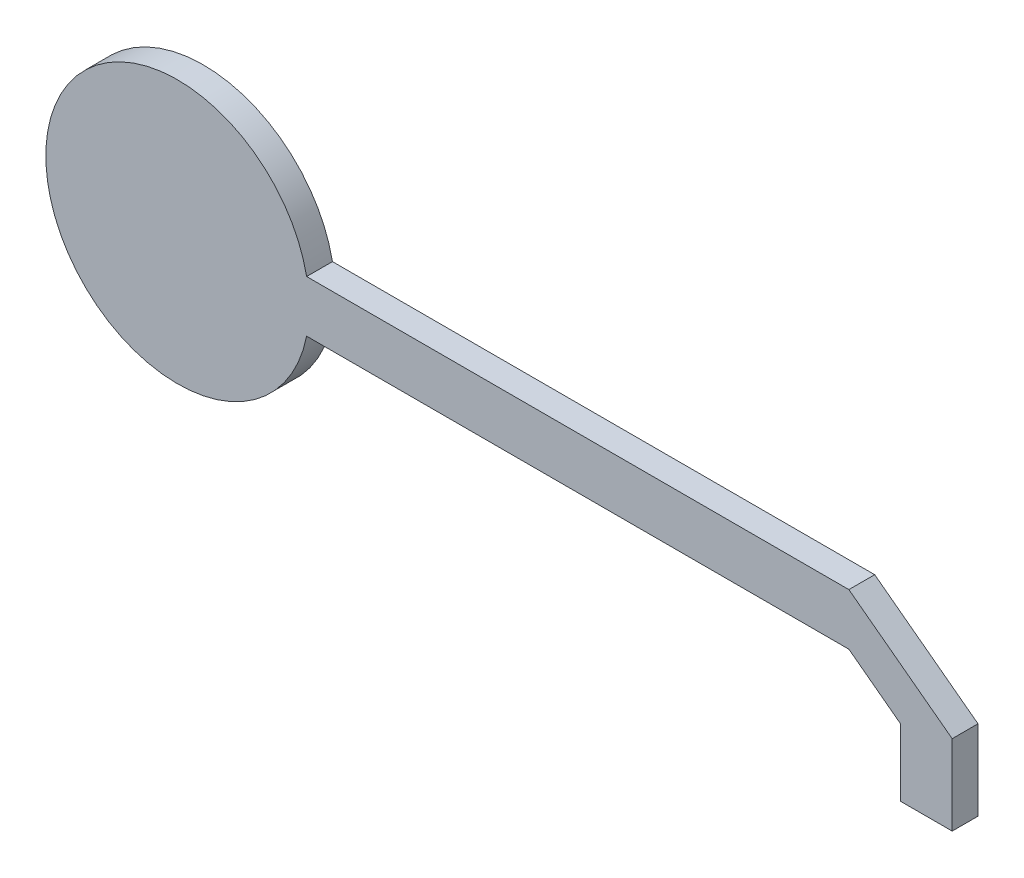
from build123d import *

# Parameters (mm, degrees)
SALIENTE_EXTRUIR1_DEPTH = 5
CROQUIS3_R              = 2.5
SALIENTE_EXTRUIR3_DEPTH = 5
CROQUIS4_R              = 5
SALIENTE_EXTRUIR4_DEPTH = 10


with BuildPart() as part:
    # Croquis1 → Saliente-Extruir1 (new body)
    with BuildSketch(Plane.XY):
        with BuildLine():
            Line((-52.49750025, 5), (52.49750025, 5))
            Line((52.49750025, 5), (72.49750025, -10))
            Line((72.49750025, -10), (72.49750025, -25.5))
            Line((72.49750025, -25.5), (62.49750025, -25.5))
            Line((62.49750025, -25.5), (62.49750025, -12.5))
            Line((62.49750025, -12.5), (52.49750025, -5))
            Line((52.49750025, -5), (-52.49750025, -5))
            ThreePointArc((-52.49750025, -5), (-103.00249975, 0), (-52.49750025, 5))
        make_face()
    extrude(amount=SALIENTE_EXTRUIR1_DEPTH)

    # Croquis3 → Saliente-Extruir3 (add)
    with BuildSketch(Plane(origin=(0, 0, 0), x_dir=(-1, 0, 0), z_dir=(0, 0, -1))):
        with Locations((77.50249975, 12.5)):
            Circle(CROQUIS3_R)
    extrude(amount=SALIENTE_EXTRUIR3_DEPTH)

    # Croquis4 → Saliente-Extruir4 (add)
    with BuildSketch(Plane(origin=(0, 0, 0), x_dir=(-1, 0, 0), z_dir=(0, 0, -1))):
        with Locations((77.50249975, 0)):
            Circle(CROQUIS4_R)
    extrude(amount=SALIENTE_EXTRUIR4_DEPTH)


solid = part.part
